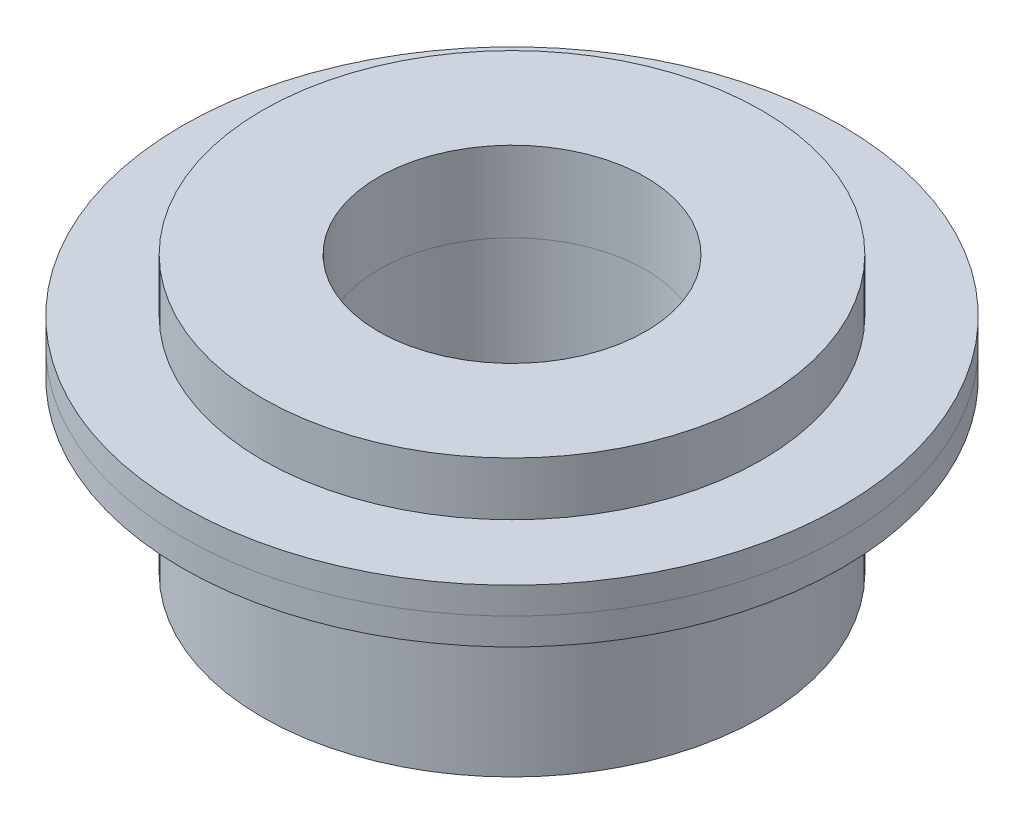
from build123d import *

# Parameters (mm, degrees)
SKETCH2_R           = 14
BOSS_EXTRUDE1_DEPTH = 9.5
SKETCH3_R           = 18.5
BOSS_EXTRUDE2_DEPTH = 1.5
SKETCH4_R           = 18.5
BOSS_EXTRUDE5_DEPTH = 1.5
SKETCH7_R           = 14
BOSS_EXTRUDE6_DEPTH = 3
SKETCH8_R           = 7.5
CUT_EXTRUDE2_DEPTH  = 16.5


with BuildPart() as part:
    # Sketch2 → Boss-Extrude1 (new body)
    with BuildSketch(Plane(origin=(0, 0, 0), x_dir=(1, 0, 0), z_dir=(0, 1, 0))):
        Circle(SKETCH2_R)
    extrude(amount=BOSS_EXTRUDE1_DEPTH)

    # Sketch3 → Boss-Extrude2 (add)
    with BuildSketch(Plane(origin=(0, 9.5, 0), x_dir=(1, 0, 0), z_dir=(0, 1, 0))):
        Circle(SKETCH3_R)
    extrude(amount=BOSS_EXTRUDE2_DEPTH)


with BuildPart() as body_2:
    # Sketch4 → Boss-Extrude5 (new body)
    with BuildSketch(Plane(origin=(0, 11, 0), x_dir=(1, 0, 0), z_dir=(0, 1, 0))):
        Circle(SKETCH4_R)
    extrude(amount=BOSS_EXTRUDE5_DEPTH)

    # Sketch7 → Boss-Extrude6 (add)
    with BuildSketch(Plane(origin=(0, 12.5, 0), x_dir=(1, 0, 0), z_dir=(0, 1, 0))):
        Circle(SKETCH7_R)
    extrude(amount=BOSS_EXTRUDE6_DEPTH)


with BuildPart() as cut_extrude2_tool:
    # Sketch8 → Cut-Extrude2 (new body, through all)
    with BuildSketch(Plane(origin=(0, 15.5, 0), x_dir=(1, 0, 0), z_dir=(0, 1, 0))):
        Circle(SKETCH8_R)
    extrude(amount=-CUT_EXTRUDE2_DEPTH)


with BuildPart() as part_1:
    add(part.part)

    # Cut-Extrude2: cut by cut_extrude2_tool
    add(cut_extrude2_tool.part, mode=Mode.SUBTRACT)


with BuildPart() as body_2_1:
    add(body_2.part)

    # Cut-Extrude2: cut by cut_extrude2_tool
    add(cut_extrude2_tool.part, mode=Mode.SUBTRACT)


solid = Compound([part_1.part, body_2_1.part])
